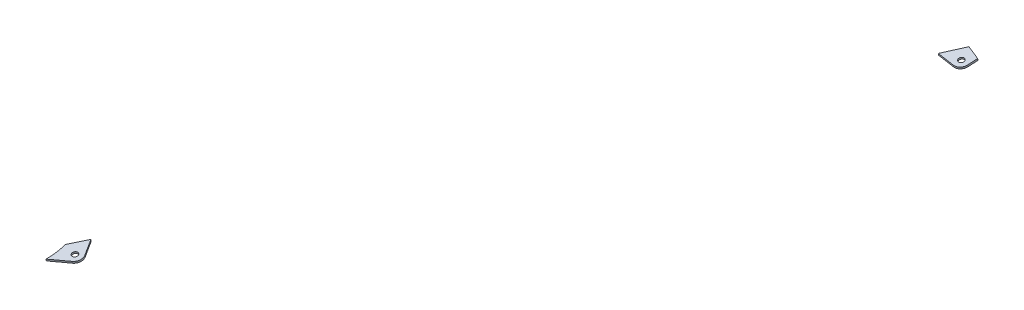
from build123d import *

# Parameters (mm, degrees)
SZKIC1_R                      = 3
DODANIE_WYCI_GNI_CIE1_DEPTH   = 2
DODANIE_WYCI_GNI_CIE1_2_DEPTH = 2


with BuildPart() as part:
    # Szkic1 → Dodanie-wyciągnięcie1 (new body)
    with BuildSketch(Plane(origin=(0, 358.092671711, 69.606164227), x_dir=(-1, 0, 0), z_dir=(0, -0.981627183, -0.190808995))):
        with BuildLine():
            Line((-1362.923797729, -419.854107682), (-1364.182603001, -410.079521535))
            add(Edge.make_bspline(
                [(-1349.308104441, -404.615300263), (-1354.327109709, -406.530701132), (-1359.305192252, -408.355661256), (-1364.182603001, -410.079521535)],
                knots=[0.918491709, 0.918491709, 0.918491709, 0.918491709, 1, 1, 1, 1], degree=3, weights=[0.850940189, 0.896217531, 0.945904135, 1]))
            add(Edge.make_bspline(
                [(-1335.135312752, -424.341477666), (-1339.857721526, -417.768694868), (-1344.581988379, -411.193298285), (-1349.308104441, -404.615300263)],
                knots=[0.966451554, 0.966451554, 0.966451554, 0.966451554, 1, 1, 1, 1], degree=3, weights=[0.999946517, 0.999963726, 0.999981554, 1]))
            Line((-1335.135312752, -424.341477666), (-1353.967495394, -426.766751785))
            ThreePointArc((-1353.967495394, -426.766751785), (-1359.877302031, -425.165340681), (-1362.923797729, -419.854107682))
        make_face()
        with Locations((-1354.98932451, -418.832278566)):
            Circle(SZKIC1_R, mode=Mode.SUBTRACT)
    extrude(amount=DODANIE_WYCI_GNI_CIE1_DEPTH)


with BuildPart() as body_2:
    # Szkic1 → Dodanie-wyci_gni_cie1 2 (new body)
    with BuildSketch(Plane(origin=(0, 358.092671711, 69.606164227), x_dir=(-1, 0, 0), z_dir=(0, -0.981627183, -0.190808995))):
        with BuildLine():
            Line((-952.848375327, -984.825791702), (-944.168784695, -969.343088606))
            add(Edge.make_bspline(
                [(-932.070864738, -985.269178293), (-936.101696367, -979.962881902), (-940.134338111, -974.654183026), (-944.168784695, -969.343088606)],
                knots=[0, 0, 0, 0, 0.028373338, 0.028373338, 0.028373338, 0.028373338], degree=3, weights=[1, 0.999984399, 0.999969241, 0.999954525]))
            add(Edge.make_bspline(
                [(-931.253435448, -1006.103231509), (-931.346908095, -1005.707936087), (-931.433937079, -1005.310748901), (-931.730758065, -1003.851080189), (-931.904919365, -1002.774169083), (-932.317793571, -999.550369722), (-932.450892162, -997.405576031), (-932.526546788, -993.121894403), (-932.467876959, -990.983044462), (-932.271293947, -987.653301408), (-932.179682868, -986.460973189), (-932.070864738, -985.269178293)],
                knots=[0.038995217, 0.038995217, 0.038995217, 0.038995217, 0.0625, 0.0625, 0.125, 0.125, 0.25, 0.25, 0.375, 0.375, 0.444789397, 0.444789397, 0.444789397, 0.444789397], degree=3))
            Line((-931.253435448, -1006.103231509), (-949.782119992, -995.71606618))
            ThreePointArc((-949.782119992, -995.71606618), (-953.570697353, -990.905971214), (-952.848375327, -984.825791702))
        make_face()
        with Locations((-945.87011042, -988.737801274)):
            Circle(SZKIC1_R, mode=Mode.SUBTRACT)
    extrude(amount=DODANIE_WYCI_GNI_CIE1_2_DEPTH)


solid = Compound([part.part, body_2.part])
